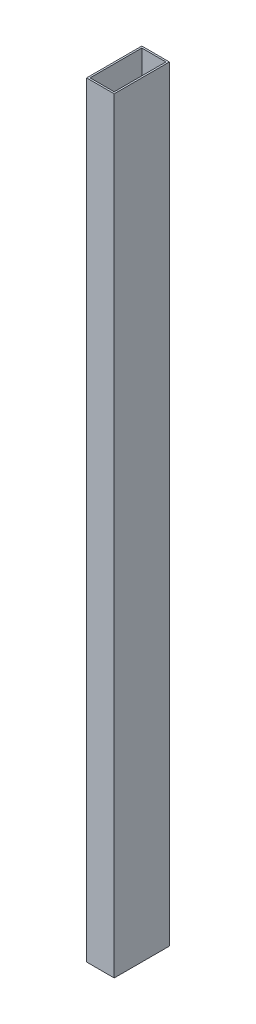
from build123d import *

# Parameters (mm, degrees)
SKETCH1_W           = 25.4
SKETCH1_H           = 50.8
SKETCH1_W_2         = 22.225
SKETCH1_H_2         = 47.625
EXTRUDE_THIN1_DEPTH = 704.85


with BuildPart() as part:
    # Sketch1 → Extrude-Thin1 (new body)
    with BuildSketch(Plane(origin=(0, 0, 0), x_dir=(1, 0, 0), z_dir=(0, 1, 0))):
        Rectangle(SKETCH1_W, SKETCH1_H)
        Rectangle(SKETCH1_W_2, SKETCH1_H_2, mode=Mode.SUBTRACT)
    extrude(amount=EXTRUDE_THIN1_DEPTH)


solid = part.part
